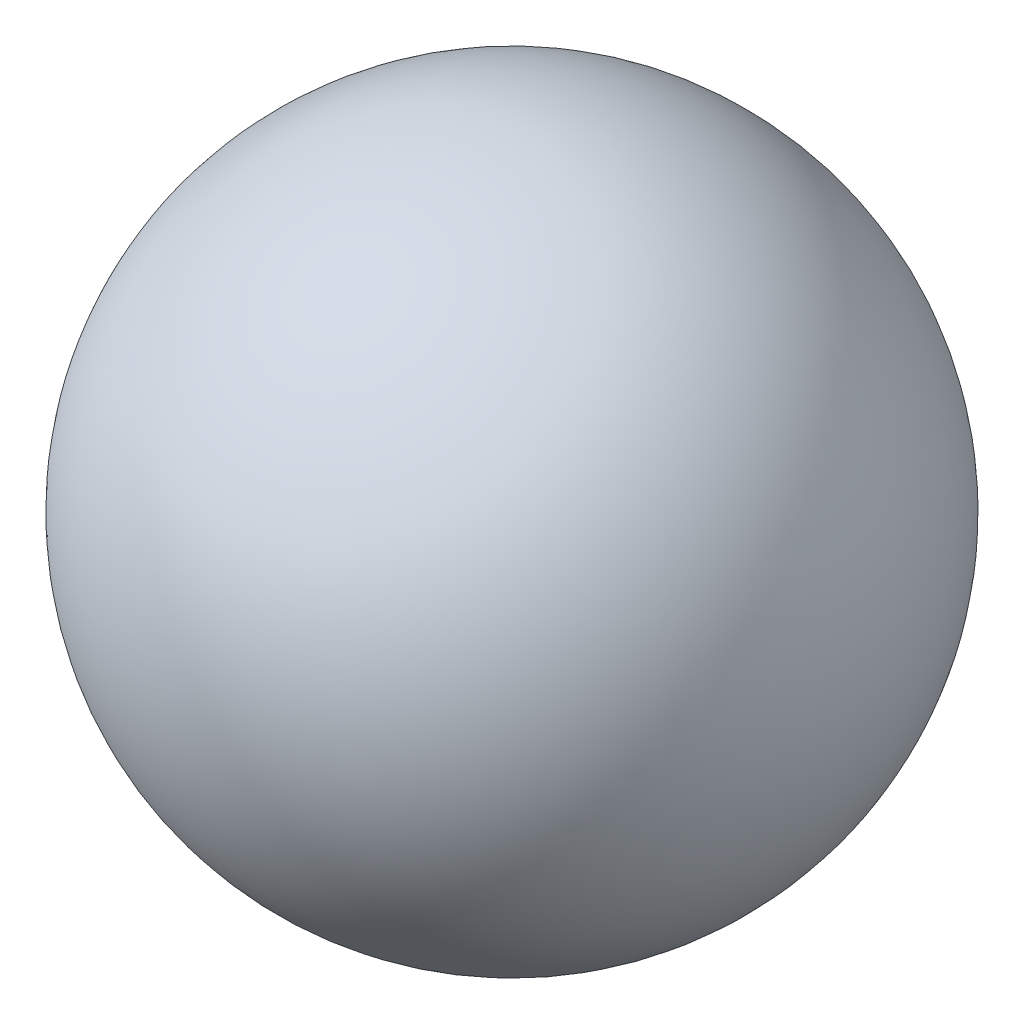
from build123d import *


with BuildPart() as part:
    # Sketch1 → Revolve1 (revolve)
    with BuildSketch(Plane.XY):
        with BuildLine():
            Line((4.5875, 9), (1.4125, 9))
            ThreePointArc((1.4125, 9), (3, 10.5875), (4.5875, 9))
        make_face()
    revolve(axis=Axis((4.5875, 9, 0), (-1, 0, 0)))


solid = part.part
